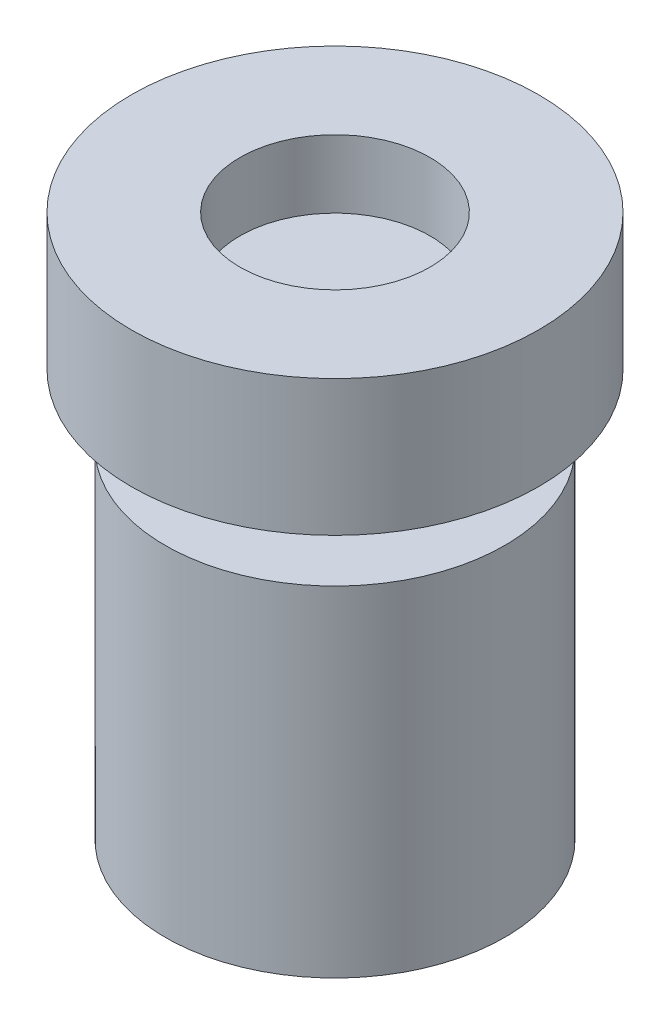
from build123d import *

# Parameters (mm, degrees)
SKETCH1_R           = 3
SKETCH1_R_2         = 1.4
BOSS_EXTRUDE1_DEPTH = 2
SKETCH1_3_R         = 1.4
BOSS_EXTRUDE2_DEPTH = 1
SKETCH5_R           = 1.5
BOSS_EXTRUDE3_DEPTH = 1
SKETCH6_R           = 2.5
BOSS_EXTRUDE4_DEPTH = 5


with BuildPart() as part:
    # Sketch1 → Boss-Extrude1 (new body)
    with BuildSketch(Plane(origin=(0, 0, 0), x_dir=(1, 0, 0), z_dir=(0, 1, 0))):
        with Locations((-0.522013312, 0.511138034)):
            Circle(SKETCH1_R)
        with Locations((-0.522013312, 0.511138034)):
            Circle(SKETCH1_R_2, mode=Mode.SUBTRACT)
    extrude(amount=BOSS_EXTRUDE1_DEPTH)

    # Sketch1_3 → Boss-Extrude2 (add)
    with BuildSketch(Plane(origin=(0, 0, 0), x_dir=(1, 0, 0), z_dir=(0, 1, 0))):
        with Locations((-0.522013312, 0.511138034)):
            Circle(SKETCH1_3_R)
    extrude(amount=BOSS_EXTRUDE2_DEPTH)

    # Sketch5 → Boss-Extrude3 (add)
    with BuildSketch(Plane.XZ):
        with Locations((-0.522013312, -0.511138034)):
            Circle(SKETCH5_R)
    extrude(amount=BOSS_EXTRUDE3_DEPTH)

    # Sketch6 → Boss-Extrude4 (add)
    with BuildSketch(Plane.XZ.offset(1)):
        with Locations((-0.522013312, -0.511138034)):
            Circle(SKETCH6_R)
    extrude(amount=BOSS_EXTRUDE4_DEPTH)


solid = part.part
